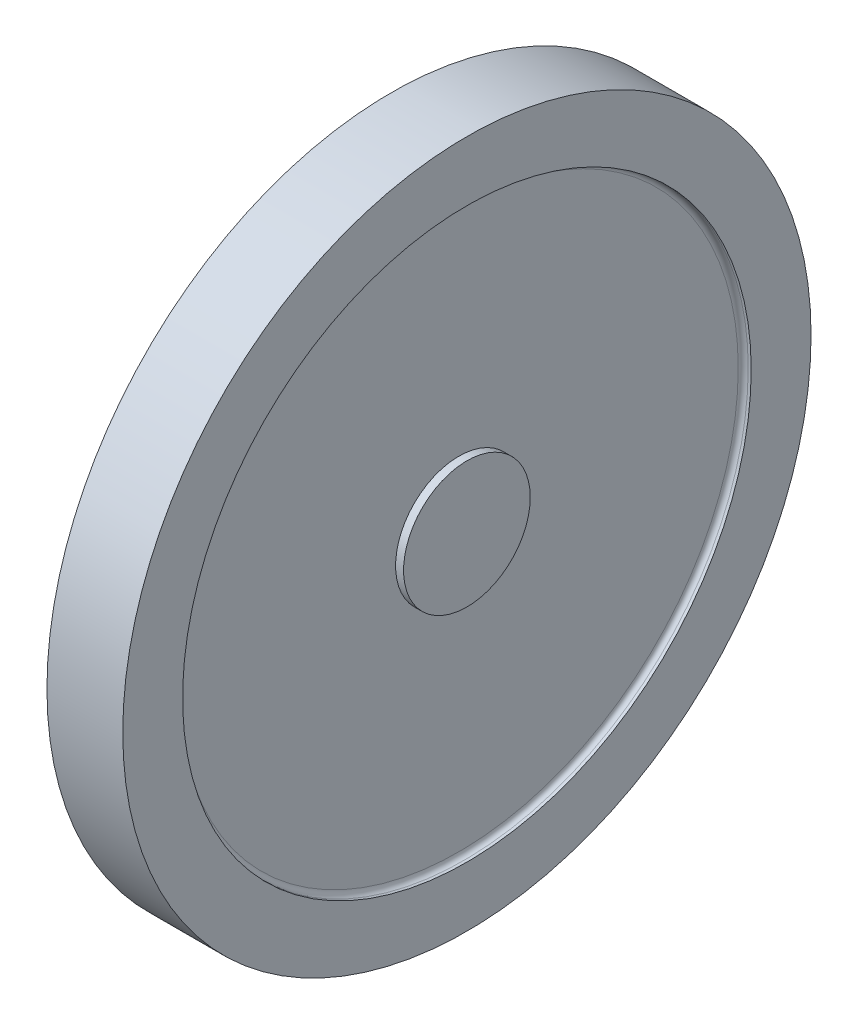
from build123d import *

# Parameters (mm, degrees)
FILLET1_R = 0.5


with BuildPart() as part:
    # Sketch3 → Revolve1 (revolve)
    with BuildSketch(Plane.XY):
        Polygon((-7.6, 28.5), (-6.8, 28.5), (-6.8, 0), (-0.8, 0), (0, 0), (0, 6.35), (-0.8, 6.35), (-0.8, 28.5), (0, 28.5), (0, 34.5), (-7.6, 34.5), align=None)
    revolve(axis=Axis((-0.8, 0, 0), (-1, 0, 0)))

    # Fillet1
    fillet1_edges = [part.edges().sort_by_distance(p)[0] for p in [
        (-6.8, -28.5, 0),
        (-0.8, -28.5, 0),
    ]]
    fillet(fillet1_edges, radius=FILLET1_R)


solid = part.part
